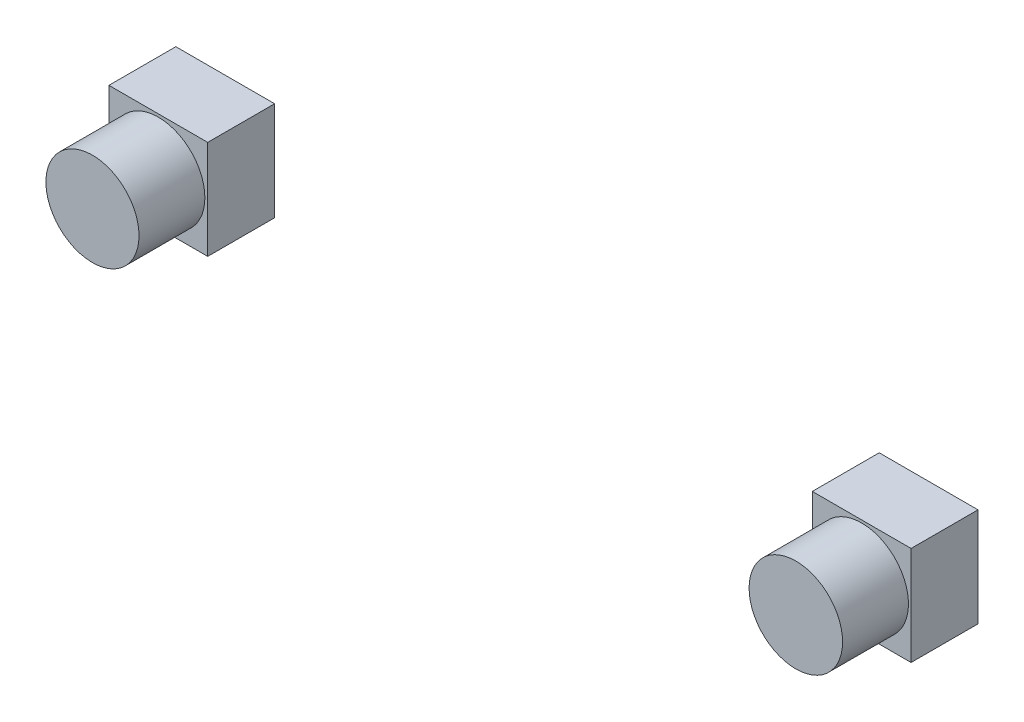
from build123d import *

# Parameters (mm, degrees)
SKETCH1_W             = 75
SKETCH1_H             = 75
BOSS_EXTRUDE1_DEPTH   = 50.8
BOSS_EXTRUDE1_2_DEPTH = 50.8
SKETCH2_R             = 35.488594607
SKETCH2_R_2           = 35.341352145
BOSS_EXTRUDE2_DEPTH   = 50


with BuildPart() as part:
    # Sketch1 → Boss-Extrude1 (new body)
    with BuildSketch(Plane.XY):
        with Locations((267.5, 672.77)):
            Rectangle(SKETCH1_W, SKETCH1_H)
    extrude(amount=BOSS_EXTRUDE1_DEPTH)



with BuildPart() as body_2:
    # Sketch1 → Boss-Extrude1 2 (new body)
    with BuildSketch(Plane.XY):
        with Locations((-266.5, 672.77)):
            Rectangle(SKETCH1_W, SKETCH1_H)
    extrude(amount=BOSS_EXTRUDE1_2_DEPTH)


with BuildPart() as part_1:
    add(part.part)

    add(body_2.part)  # Boss-Extrude2 merges body 2
    # Sketch2 → Boss-Extrude2 (add)
    with BuildSketch(Plane.XY.offset(50.8)):
        with Locations((267.5, 672.77)):
            Circle(SKETCH2_R)
        with Locations((-266.5, 672.77)):
            Circle(SKETCH2_R_2)
    extrude(amount=BOSS_EXTRUDE2_DEPTH)


solid = part_1.part
